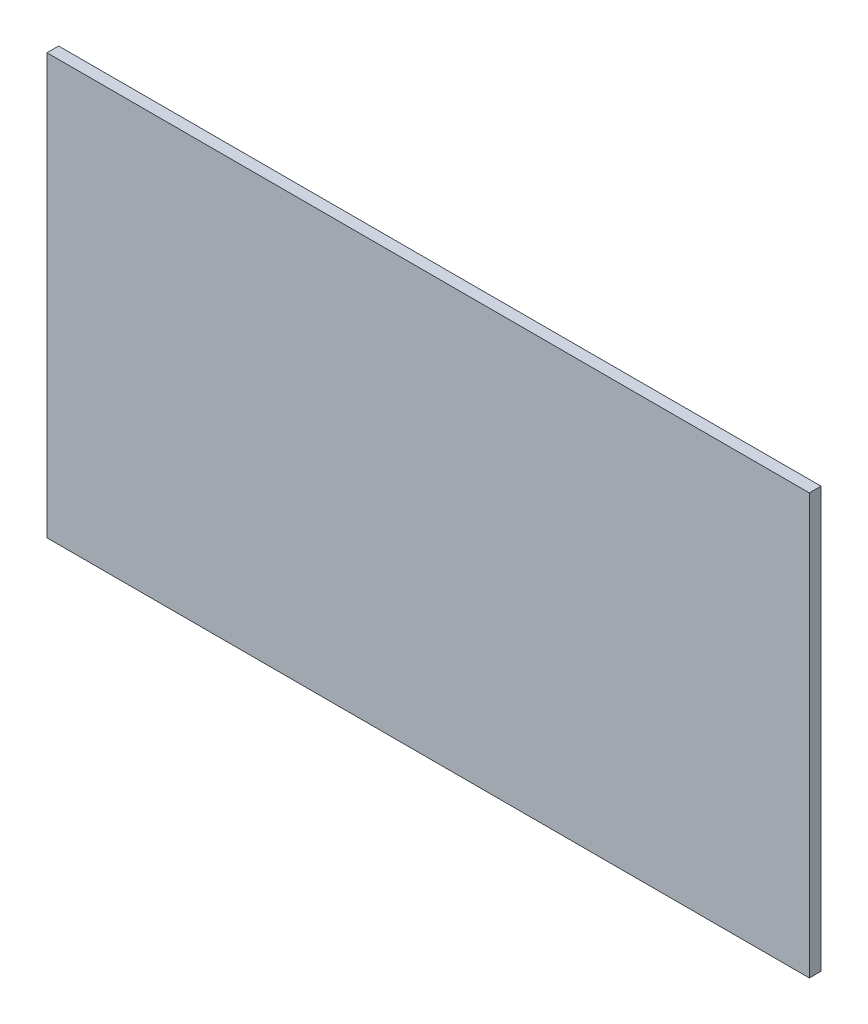
from build123d import *

# Parameters (mm, degrees)
SKETCH1_W           = 196
SKETCH1_H           = 108
BOSS_EXTRUDE1_DEPTH = 3


with BuildPart() as part:
    # Sketch1 → Boss-Extrude1 (new body)
    with BuildSketch(Plane.XY):
        with Locations((98, 54)):
            Rectangle(SKETCH1_W, SKETCH1_H)
    extrude(amount=BOSS_EXTRUDE1_DEPTH)


solid = part.part
